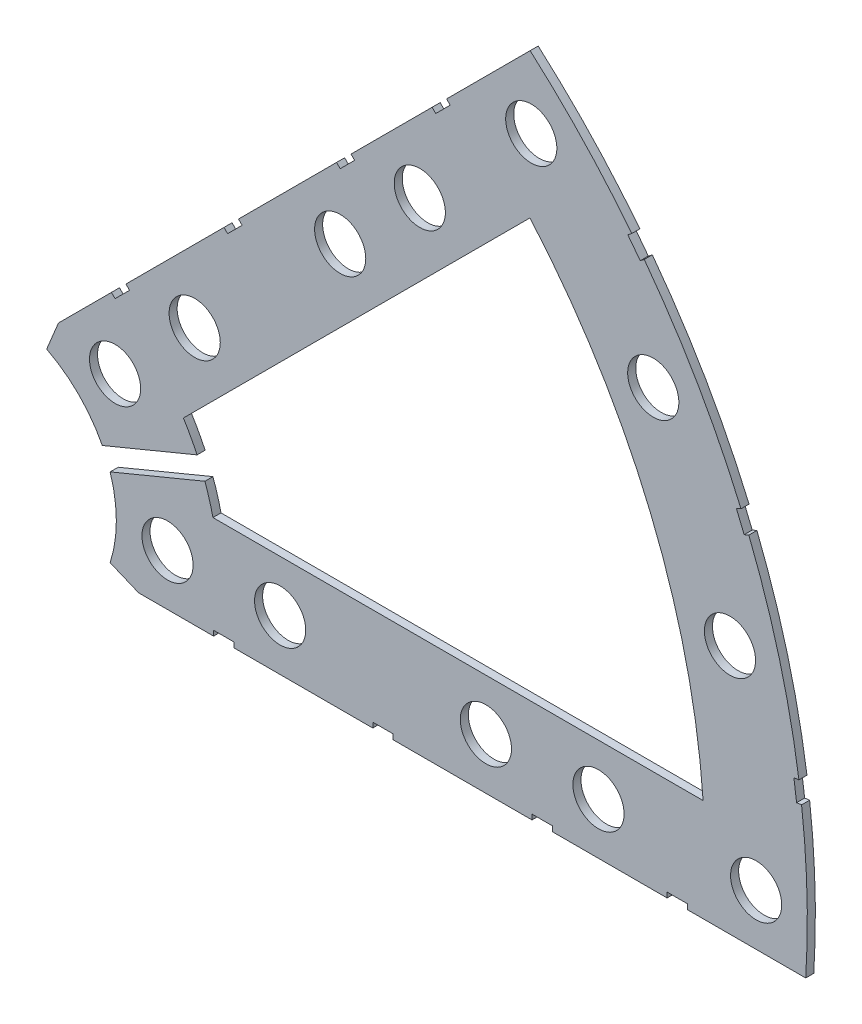
from build123d import *

# Parameters (mm, degrees)
BOSS_EXTRUDE1_DEPTH = 1
SKETCH2_R           = 3.175
CUT_EXTRUDE1_DEPTH  = 2
SKETCH3_W           = 2.54
SKETCH3_H           = 0.635
CUT_EXTRUDE2_DEPTH  = 2


with BuildPart() as part:
    # Sketch1 → Boss-Extrude1 (new body)
    with BuildSketch(Plane.XY):
        with BuildLine():
            Line((67.21146711, 76.191723231), (8.696654013, 17.676910134))
            Line((8.696654013, 17.676910134), (7.228954972, 14.133571205))
            ThreePointArc((7.228954972, 14.133571205), (14.666587579, 6.075099489), (15.105587123, -4.88230096))
            Line((15.105587123, -4.88230096), (18.648926052, -6.35))
            Line((18.648926052, -6.35), (101.401368334, -6.35))
            ThreePointArc((101.401368334, -6.35), (93.866160503, 38.880636728), (67.21146711, 76.191723231))
        make_face()
        with BuildLine():
            Line((88.672924278, 6.35), (27.86051193, 6.35))
            ThreePointArc((27.86051193, 6.35), (26.399857642, 10.93517908), (24.190484974, 15.210228852))
            Line((24.190484974, 15.210228852), (67.191354125, 58.211098004))
            ThreePointArc((67.191354125, 58.211098004), (82.13289044, 34.020557137), (88.672924278, 6.35))
        make_face(mode=Mode.SUBTRACT)
    extrude(amount=BOSS_EXTRUDE1_DEPTH)

    # Sketch2 → Cut-Extrude1 (cut, through all)
    with BuildSketch(Plane.XY.offset(1)):
        with Locations((22.225, 0)):
            Circle(SKETCH2_R)
        with Locations((36.195, 0)):
            Circle(SKETCH2_R)
        with Locations((61.722, 0)):
            Circle(SKETCH2_R)
        with Locations((75.692, 0)):
            Circle(SKETCH2_R)
        with Locations((95.25, 0)):
            Circle(SKETCH2_R)
        with Locations((15.715448212, 15.715448212)):
            Circle(SKETCH2_R)
        with Locations((25.593729945, 25.593729945)):
            Circle(SKETCH2_R)
        with Locations((43.644044748, 43.644044748)):
            Circle(SKETCH2_R)
        with Locations((53.522326482, 53.522326482)):
            Circle(SKETCH2_R)
        with Locations((92.004434954, 24.652514046)):
            Circle(SKETCH2_R)
        with Locations((82.48891971, 47.625)):
            Circle(SKETCH2_R)
        with Locations((67.351920908, 67.351920908)):
            Circle(SKETCH2_R)
    extrude(amount=-CUT_EXTRUDE1_DEPTH, mode=Mode.SUBTRACT)

    # Sketch3 → Cut-Extrude2 (cut, through all)
    with BuildSketch(Plane.XY.offset(1)):
        Polygon((15.266435406, 24.246691527), (17.06248663, 26.042742751), (17.511499436, 25.593729945), (15.715448212, 23.797678721), align=None)
        Polygon((44.991083167, 53.971339288), (43.195031942, 52.175288063), (43.644044748, 51.726275257), (45.440095973, 53.522326482), align=None)
        with Locations((29.21, -6.0325)):
            Rectangle(SKETCH3_W, SKETCH3_H)
        with Locations((68.707, -6.0325)):
            Rectangle(SKETCH3_W, SKETCH3_H)
        Polygon((29.230733674, 38.210989795), (31.026784898, 40.007041019), (31.475797704, 39.558028213), (29.67974648, 37.761976989), align=None)
        Polygon((56.845021246, 65.825277367), (55.048970022, 64.029226143), (55.497982828, 63.580213337), (57.294034052, 65.376264561), align=None)
        with Locations((48.9585, -6.0325)):
            Rectangle(SKETCH3_W, SKETCH3_H)
        with Locations((85.471, -6.0325)):
            Rectangle(SKETCH3_W, SKETCH3_H)
        Polygon((99.935462164, 14.437711971), (100.266998693, 11.919442024), (101.526133667, 12.085210288), (101.194597138, 14.603480236), align=None)
        Polygon((93.765504959, 37.464305742), (94.938831965, 37.950313702), (93.966816047, 40.296967714), (92.793489041, 39.810959755), align=None)
        Polygon((79.327792988, 62.471156422), (80.874047017, 60.456038938), (81.88160576, 61.229165953), (80.33535173, 63.244283437), align=None)
        Polygon((13.979268531, 4.415764523), (28.059192607, 10.247860033), (27.087176689, 12.594514045), (13.007252613, 6.762418536), align=None)
    extrude(amount=-CUT_EXTRUDE2_DEPTH, mode=Mode.SUBTRACT)


solid = part.part
